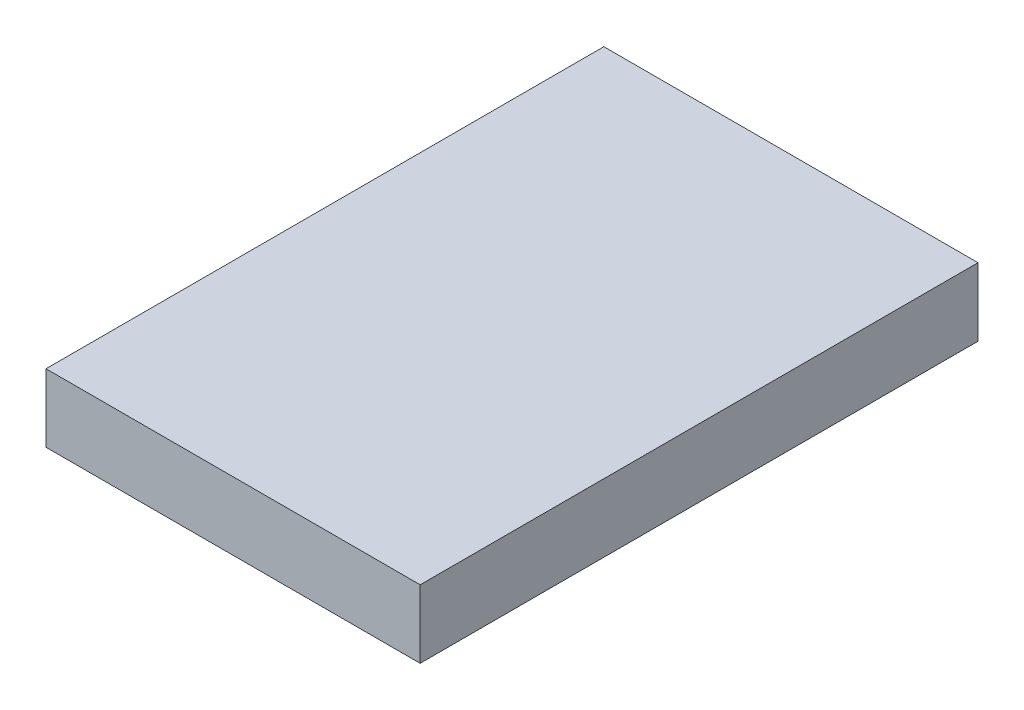
from build123d import *

# Parameters (mm, degrees)
SKETCH1_W           = 55
SKETCH1_H           = 82
BOSS_EXTRUDE1_DEPTH = 10


with BuildPart() as part:
    # Sketch1 → Boss-Extrude1 (new body)
    with BuildSketch(Plane(origin=(0, 0, 0), x_dir=(1, 0, 0), z_dir=(0, 1, 0))):
        Rectangle(SKETCH1_W, SKETCH1_H)
    extrude(amount=BOSS_EXTRUDE1_DEPTH)


solid = part.part
